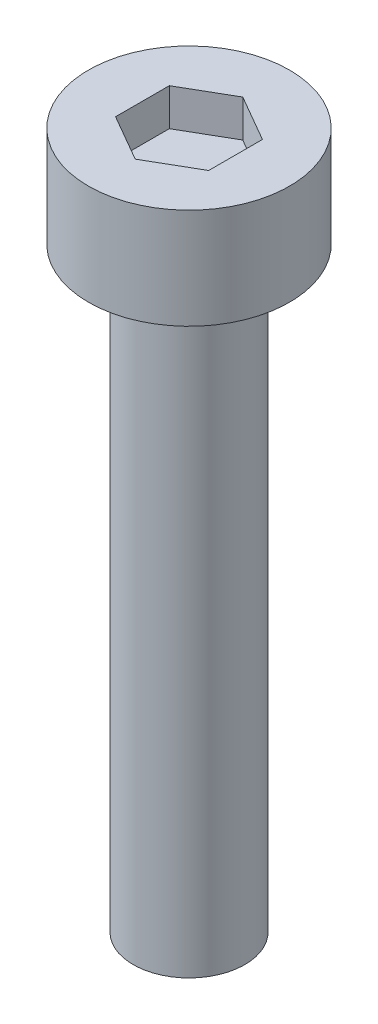
from build123d import *

# Parameters (mm, degrees)
SKETCH1_R           = 2.7
BOSS_EXTRUDE1_DEPTH = 2.7
CUT_EXTRUDE1_DEPTH  = 1
SKETCH3_R           = 1.5
BOSS_EXTRUDE2_DEPTH = 16


with BuildPart() as part:
    # Sketch1 → Boss-Extrude1 (new body)
    with BuildSketch(Plane(origin=(0, 0, 0), x_dir=(1, 0, 0), z_dir=(0, 1, 0))):
        Circle(SKETCH1_R)
    extrude(amount=BOSS_EXTRUDE1_DEPTH)

    # Sketch2 → Cut-Extrude1 (cut)
    with BuildSketch(Plane(origin=(0, 2.7, 0), x_dir=(1, 0, 0), z_dir=(0, 1, 0))):
        Polygon((0, 1.443375673), (-1.25, 0.721687836), (-1.25, -0.721687836), (0, -1.443375673), (1.25, -0.721687836), (1.25, 0.721687836), align=None)
    extrude(amount=-CUT_EXTRUDE1_DEPTH, mode=Mode.SUBTRACT)

    # Sketch3 → Boss-Extrude2 (add)
    with BuildSketch(Plane.XZ):
        Circle(SKETCH3_R)
    extrude(amount=BOSS_EXTRUDE2_DEPTH)


solid = part.part
